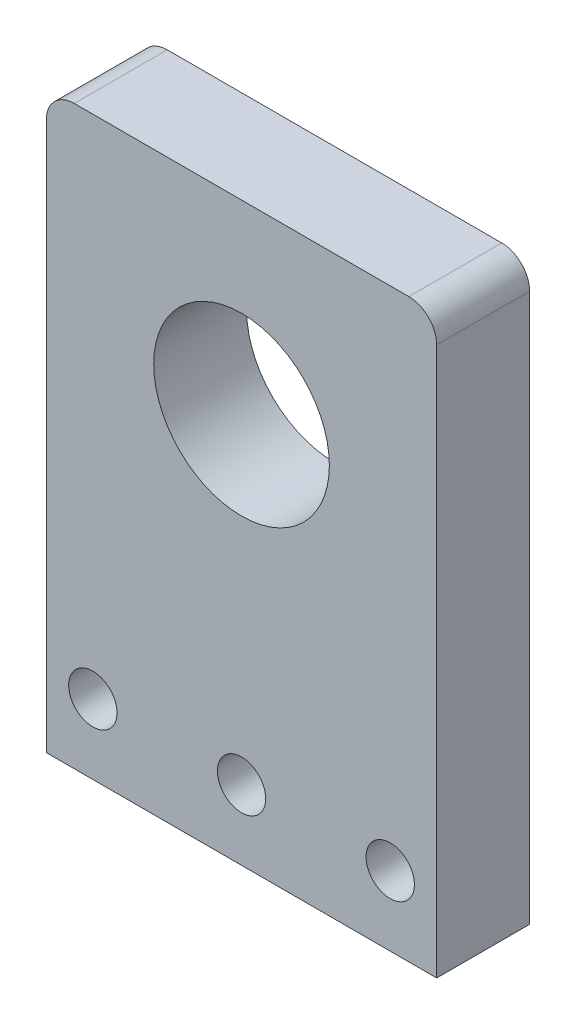
from build123d import *

# Parameters (mm, degrees)
SKETCH1_W           = 42
SKETCH1_H           = 62
SKETCH1_R           = 4.15
BOSS_EXTRUDE1_DEPTH = 10
FILLET1_R           = 3
SKETCH2_R           = 2.6
CUT_EXTRUDE1_DEPTH  = 11
SKETCH3_R           = 9.45
CUT_EXTRUDE2_DEPTH  = 10


with BuildPart() as part:
    # Sketch1 → Boss-Extrude1 (new body)
    with BuildSketch(Plane.XY):
        with Locations((21, 31)):
            Rectangle(SKETCH1_W, SKETCH1_H)
        with Locations((21, 42)):
            Circle(SKETCH1_R, mode=Mode.SUBTRACT)
    extrude(amount=BOSS_EXTRUDE1_DEPTH)

    # Fillet1
    fillet1_edges = [part.edges().sort_by_distance(p)[0] for p in [
        (0, 62, 5),
        (42, 62, 5),
    ]]
    fillet(fillet1_edges, radius=FILLET1_R)

    # Sketch2 → Cut-Extrude1 (cut, through all)
    with BuildSketch(Plane.XY.offset(10)):
        with Locations((5, 7.5)):
            Circle(SKETCH2_R)
        with Locations((21, 7.5)):
            Circle(SKETCH2_R)
        with Locations((37, 7.5)):
            Circle(SKETCH2_R)
    extrude(amount=-CUT_EXTRUDE1_DEPTH, mode=Mode.SUBTRACT)

    # Sketch3 → Cut-Extrude2 (cut)
    with BuildSketch(Plane.XY.offset(10)):
        with Locations((21, 42)):
            Circle(SKETCH3_R)
    extrude(amount=-CUT_EXTRUDE2_DEPTH, mode=Mode.SUBTRACT)


solid = part.part
